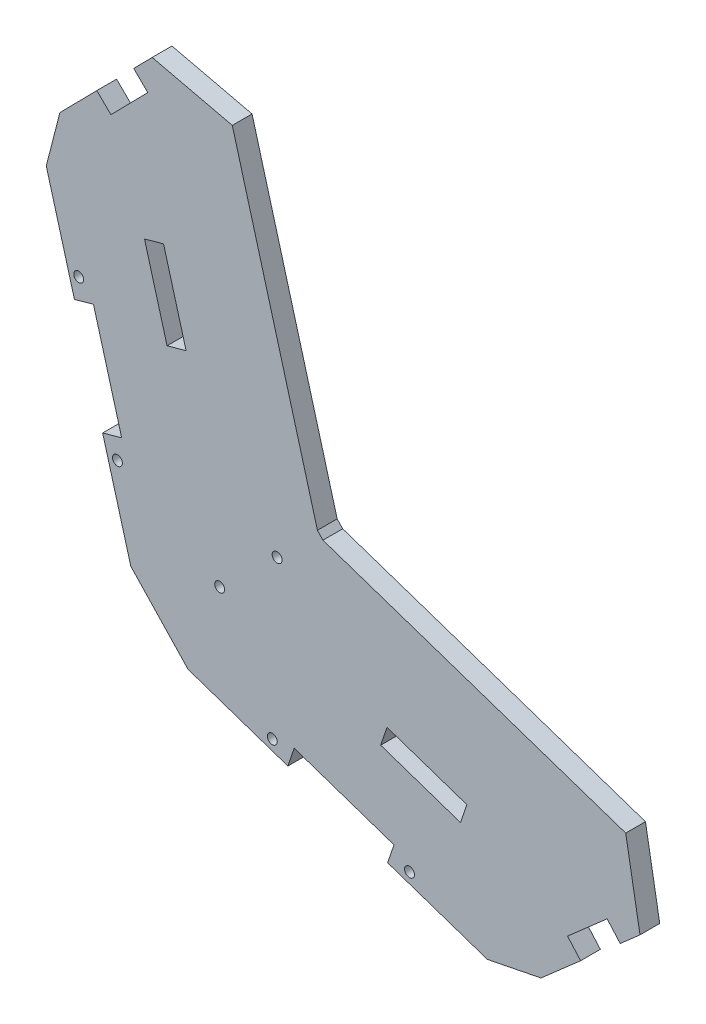
from build123d import *

# Parameters (mm, degrees)
SALIENTE_EXTRUIR1_DEPTH = 5
CROQUIS2_R              = 1.25
CORTAR_EXTRUIR1_DEPTH   = 10
CORTAR_EXTRUIR2_DEPTH   = 22
CORTAR_EXTRUIR3_DEPTH   = 10
SALIENTE_EXTRUIR2_DEPTH = 5
CROQUIS7_R              = 1.25
CORTAR_EXTRUIR4_DEPTH   = 10
SALIENTE_EXTRUIR3_DEPTH = 5
CORTAR_EXTRUIR7_DEPTH   = 10


with BuildPart() as part:
    # Croquis1 → Saliente-Extruir1 (new body)
    with BuildSketch(Plane.XY):
        Polygon((94.71302301, -28.670259317), (124.784571975, -2.294096918), (121.487551675, 1.464846702), (33.971255169, 31.023525729), (29.162783478, 36.110627065), (4.554636507, 125.156882092), (0.987169784, 128.660192123), (-27.039310471, 100.120458339), (-30.489528096, 86.717422014), (-9.088639631, 9.652046375), (5.402210696, -5.678484568), (81.141270829, -31.381887447), align=None)
    extrude(amount=SALIENTE_EXTRUIR1_DEPTH)

    # Croquis2 → Cortar-Extruir1 (cut)
    with BuildSketch(Plane.XY.offset(5)):
        with Locations((27.933375513, 30.132453761)):
            Circle(CROQUIS2_R)
        with Locations((13.398800269, 16.393963215)):
            Circle(CROQUIS2_R)
    extrude(amount=-CORTAR_EXTRUIR1_DEPTH, mode=Mode.SUBTRACT)

    # Croquis3 → Cortar-Extruir2 (cut)
    with BuildSketch(Plane.XY.offset(5)):
        Polygon((32.261175329, -9.513472178), (57.513309445, -18.083234934), (55.906478928, -22.818010081), (30.654344812, -14.248247324), align=None)
        Polygon((101.439852365, -16.119261564), (111.46370202, -7.327207431), (114.76072232, -11.086151051), (104.736872665, -19.878205184), align=None)
        Polygon((-11.401313453, 36.666602778), (-18.536576351, 62.360943293), (-23.354265197, 61.023081499), (-16.219002299, 35.328740985), align=None)
        Polygon((-14.129683663, 106.130392902), (-4.787523578, 115.643637497), (-8.354990301, 119.146947529), (-17.697150386, 109.633702934), align=None)
    extrude(amount=-CORTAR_EXTRUIR2_DEPTH, mode=Mode.SUBTRACT)

    # Croquis4 → Cortar-Extruir3 (cut)
    with BuildSketch(Plane.XY.offset(5)):
        Polygon((-0.808419356, 84.479263676), (-5.626108202, 83.141401882), (0.082102116, 62.58592947), (4.899790963, 63.923791264), align=None)
        Polygon((55.750831206, 6.80326974), (54.144000689, 2.068494593), (74.345707981, -4.787315612), (75.952538498, -0.052540465), align=None)
    extrude(amount=-CORTAR_EXTRUIR3_DEPTH, mode=Mode.SUBTRACT)

    # Croquis5 → Saliente-Extruir2 (add)
    with BuildSketch(Plane.XY.offset(5)):
        Polygon((4.554636507, 125.156882092), (9.373993305, 126.488722946), (33.650829441, 38.641338728), (36.750129482, 35.362447971), (123.087510452, 6.201948338), (121.487551675, 1.464846702), (33.971255169, 31.023525729), (29.162783478, 36.110627065), align=None)
    extrude(amount=-SALIENTE_EXTRUIR2_DEPTH)

    # Croquis7 → Cortar-Extruir4 (cut)
    with BuildSketch(Plane(origin=(0, 0, 0), x_dir=(-1, 0, 0), z_dir=(0, 0, -1))):
        with Locations((-61.444669333, -22.057453024)):
            Circle(CROQUIS7_R)
        with Locations((-26.722984924, -10.274029234)):
            Circle(CROQUIS7_R)
        with Locations((12.472296082, 31.179983035)):
            Circle(CROQUIS7_R)
        with Locations((22.283282568, 66.509701242)):
            Circle(CROQUIS7_R)
    extrude(amount=-CORTAR_EXTRUIR4_DEPTH, mode=Mode.SUBTRACT)

    # Croquis8 → Saliente-Extruir3 (add)
    with BuildSketch(Plane(origin=(0, 0, 0), x_dir=(-1, 0, 0), z_dir=(0, 0, -1))):
        Polygon((-33.650829441, 38.641338728), (-9.373993305, 126.488722946), (-14.193350102, 127.8205638), (-38.138875404, 41.172050391), (-39.529003796, 39.701370213), (-124.68746923, 10.939049974), (-123.087510452, 6.201948338), (-36.750129482, 35.362447971), align=None)
    extrude(amount=-SALIENTE_EXTRUIR3_DEPTH)

    # Croquis9 → Cortar-Extruir7 (cut)
    with BuildSketch(Plane(origin=(0, 0, 0), x_dir=(-1, 0, 0), z_dir=(0, 0, -1))):
        Polygon((-119.772647147, -6.690123985), (-116.160686285, 13.818975774), (-124.68746923, 10.939049974), (-121.487551675, 1.464846702), (-124.784571975, -2.294096918), align=None)
        Polygon((3.683910258, 123.903569826), (-16.59066364, 119.145721565), (-14.193350102, 127.8205638), (-4.554636507, 125.156882092), (-0.987169784, 128.660192123), align=None)
    extrude(amount=-CORTAR_EXTRUIR7_DEPTH, mode=Mode.SUBTRACT)


solid = part.part
